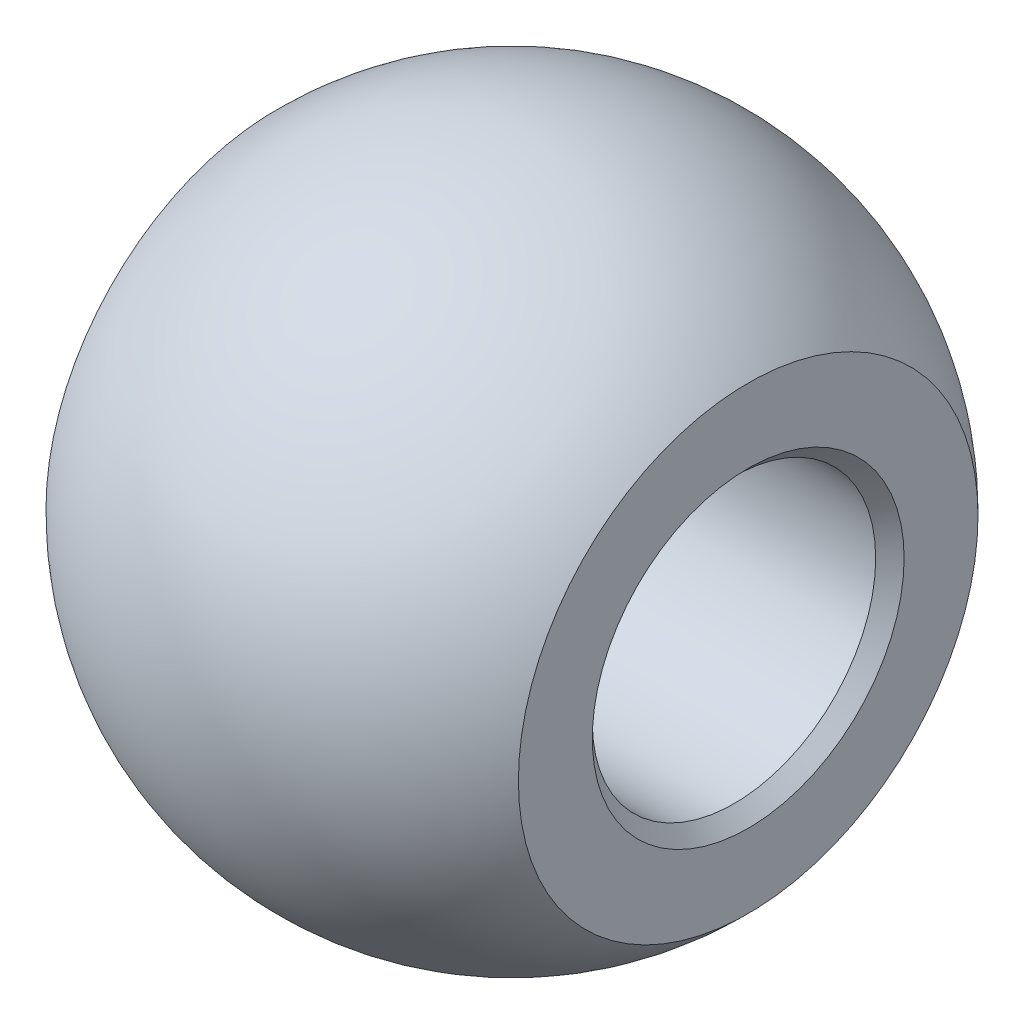
from build123d import *

# Parameters (mm, degrees)
SKETCH2_R               = 2.38125
CUT_EXTRUDE1_DEPTH      = 6.5372
CUT_EXTRUDE1_DEPTH_BACK = 6.5372
CUT_EXTRUDE2_START      = 3.96875
SKETCH3_R               = 5
CUT_EXTRUDE2_DEPTH      = 2.030273132
CHAMFER1_SIZE           = 0.23876


with BuildPart() as part:
    # Sketch1 → Revolve1 (revolve)
    with BuildSketch(Plane.XY):
        with BuildLine():
            Line((0, 5.5372), (0, -5.5372))
            ThreePointArc((0, -5.5372), (-5.5372, 0), (0, 5.5372))
        make_face()
    revolve(axis=Axis((0, 5.5372, 0), (0, -1, 0)))

    # Sketch2 → Cut-Extrude1 (cut, two sides)
    with BuildSketch(Plane(origin=(0, 0, 0), x_dir=(0, 0, -1), z_dir=(1, 0, 0))) as cut_extrude1_sk:
        Circle(SKETCH2_R)
    extrude(amount=CUT_EXTRUDE1_DEPTH, mode=Mode.SUBTRACT)
    extrude(cut_extrude1_sk.sketch, amount=-CUT_EXTRUDE1_DEPTH_BACK, mode=Mode.SUBTRACT)

    # Sketch3 → Cut-Extrude2 (cut, through all)
    with BuildSketch(Plane(origin=(0, 0, 0), x_dir=(0, 0, -1), z_dir=(1, 0, 0)).offset(CUT_EXTRUDE2_START)):
        Circle(SKETCH3_R)
    cut_extrude2 = extrude(amount=CUT_EXTRUDE2_DEPTH, mode=Mode.SUBTRACT)

    # Mirror1: Cut-Extrude2 across plane
    add(cut_extrude2.mirror(Plane(origin=(0, 0, 0), x_dir=(0, 0, 1), z_dir=(1, 0, 0))), mode=Mode.SUBTRACT)

    # Chamfer1
    chamfer1_edges = [part.edges().sort_by_distance(p)[0] for p in [
        (3.96875, 0, 2.38125),
        (-3.96875, 0, 2.38125),
    ]]
    chamfer(chamfer1_edges, length=CHAMFER1_SIZE)


solid = part.part
